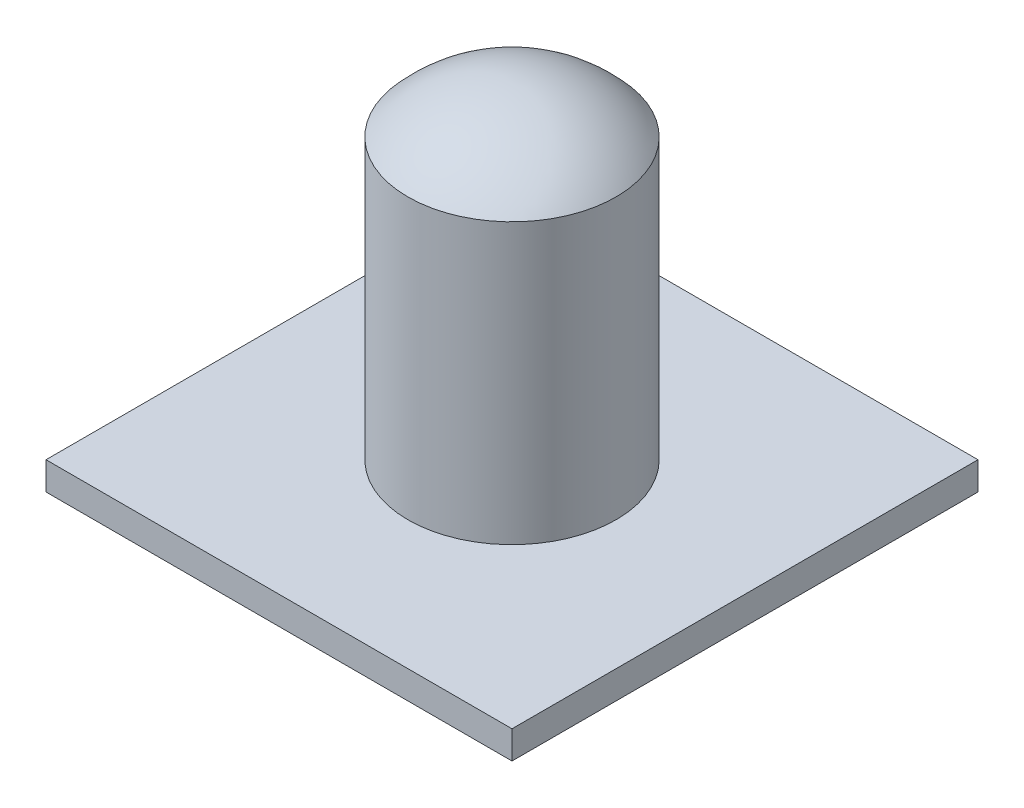
from build123d import *

# Parameters (mm, degrees)
SKETCH3_W           = 38.1
SKETCH3_H           = 38.1
BOSS_EXTRUDE1_DEPTH = 2.286
SKETCH4_R           = 8.509
BOSS_EXTRUDE2_DEPTH = 22.86
DOME2_FACE_RADIUS   = 8.509
DOME2_HEIGHT        = 3.81


with BuildPart() as part:
    # Sketch3 → Boss-Extrude1 (new body)
    with BuildSketch(Plane(origin=(0, 0, 0), x_dir=(1, 0, 0), z_dir=(0, 1, 0))):
        Rectangle(SKETCH3_W, SKETCH3_H)
    extrude(amount=BOSS_EXTRUDE1_DEPTH)

    # Sketch4 → Boss-Extrude2 (add)
    with BuildSketch(Plane(origin=(0, 2.286, 0), x_dir=(1, 0, 0), z_dir=(0, 1, 0))):
        Circle(SKETCH4_R)
    extrude(amount=BOSS_EXTRUDE2_DEPTH)

    # Dome2: a dome of height H over a round flat face of radius A is a cap of a sphere of radius (A * A + H * H) / (2 * H)
    dome2_r = (DOME2_FACE_RADIUS * DOME2_FACE_RADIUS + DOME2_HEIGHT * DOME2_HEIGHT) / (2 * DOME2_HEIGHT)
    dome2_base = Plane((0, 25.146, 0), z_dir=(0, 1, 0))
    with Locations(dome2_base.offset(DOME2_HEIGHT - dome2_r)):
        dome2_ball = Sphere(dome2_r, mode=Mode.PRIVATE)
    add(split(dome2_ball, bisect_by=dome2_base, keep=Keep.TOP, mode=Mode.PRIVATE))


solid = part.part
